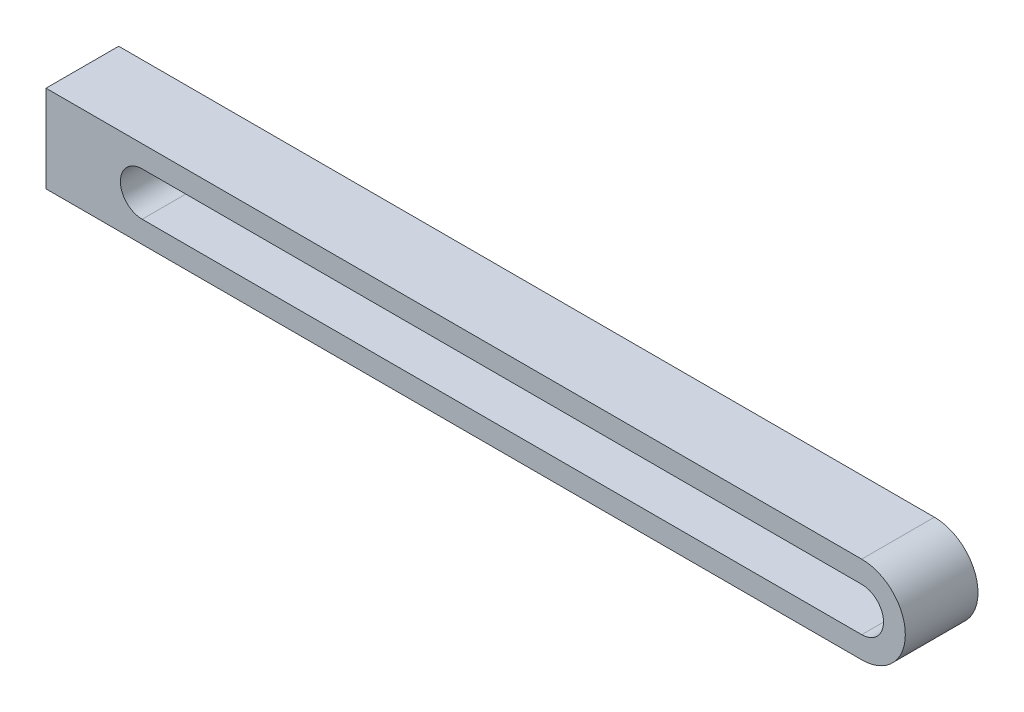
from build123d import *

# Parameters (mm, degrees)
BOSS_EXTRUDE1_DEPTH = 5


with BuildPart() as part:
    # Sketch2 → Boss-Extrude1 (new body)
    with BuildSketch(Plane.XY):
        with BuildLine():
            Line((0, 3), (49.5, 3))
            ThreePointArc((49.5, 3), (52.5, 0), (49.5, -3))
            Line((49.5, -3), (3, -3))
            Line((3, -3), (-6.616826065, -3))
            Line((-6.616826065, -3), (-6.616826065, 3))
            Line((-6.616826065, 3), (0, 3))
        make_face()
        with BuildLine():
            Line((0, -1.5), (49.5, -1.5))
            ThreePointArc((49.5, -1.5), (51, 0), (49.5, 1.5))
            Line((49.5, 1.5), (0, 1.5))
            ThreePointArc((0, 1.5), (-1.5, 0), (0, -1.5))
        make_face(mode=Mode.SUBTRACT)
    extrude(amount=BOSS_EXTRUDE1_DEPTH)


solid = part.part
